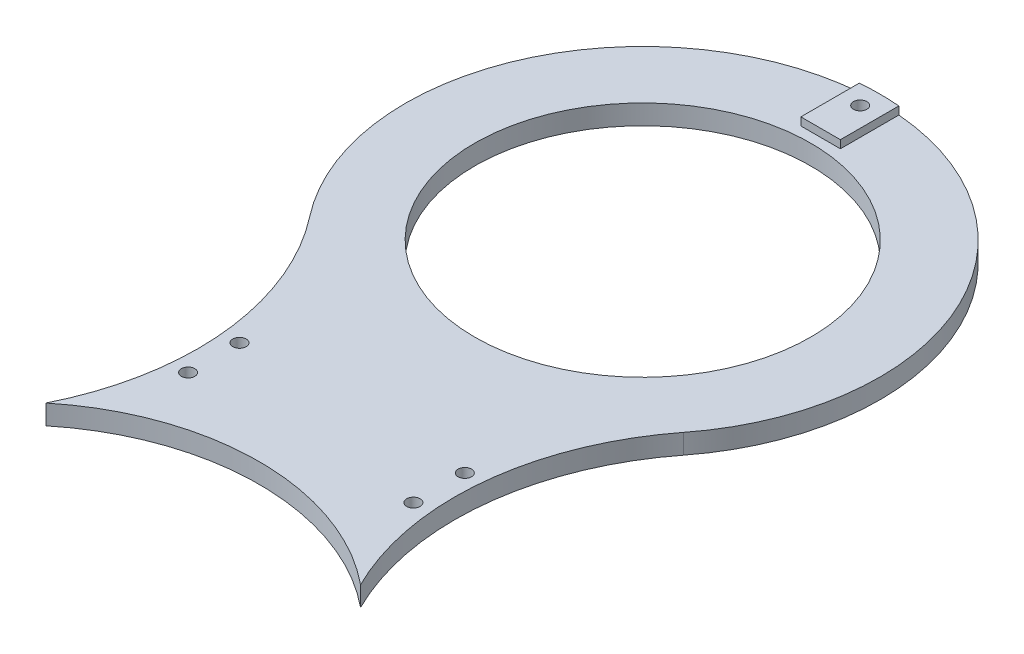
from build123d import *

# Parameters (mm, degrees)
CROQUIS1_R              = 42.5
SALIENTE_EXTRUIR1_DEPTH = 5
SALIENTE_EXTRUIR2_DEPTH = 2
CROQUIS3_R              = 1.7
CORTAR_EXTRUIR1_DEPTH   = 21
CROQUIS4_R              = 2.95
CORTAR_EXTRUIR2_DEPTH   = 3


with BuildPart() as part:
    # Croquis1 → Saliente-Extruir1 (new body)
    with BuildSketch(Plane(origin=(0, 0, 0), x_dir=(1, 0, 0), z_dir=(0, 1, 0))):
        with BuildLine():
            ThreePointArc((39.782879484, 48.85), (0, 63), (-39.782879484, 48.85))
            ThreePointArc((-39.782879484, 48.85), (-32.82545617, 87.047566078), (-47.293763221, 123.077107909))
            ThreePointArc((-47.293763221, 123.077107909), (0, 220), (47.293763221, 123.077107909))
            ThreePointArc((47.293763221, 123.077107909), (32.82545617, 87.047566078), (39.782879484, 48.85))
        make_face()
        with Locations((0, 160)):
            Circle(CROQUIS1_R, mode=Mode.SUBTRACT)
    extrude(amount=SALIENTE_EXTRUIR1_DEPTH)

    # Croquis2 → Saliente-Extruir2 (add)
    with BuildSketch(Plane(origin=(0, 5, 0), x_dir=(1, 0, 0), z_dir=(0, 1, 0))):
        with BuildLine():
            Line((5, 205), (-5, 205))
            Line((-5, 205), (-5, 219.791303716))
            ThreePointArc((-5, 219.791303716), (0, 220), (5, 219.791303716))
            Line((5, 219.791303716), (5, 205))
        make_face()
    extrude(amount=SALIENTE_EXTRUIR2_DEPTH)

    # Croquis3 → Cortar-Extruir1 (cut)
    with BuildSketch(Plane(origin=(0, 7, 0), x_dir=(1, 0, 0), z_dir=(0, 1, 0))):
        with Locations((0, 215)):
            Circle(CROQUIS3_R)
        with Locations((-28.5, 86.5)):
            Circle(CROQUIS3_R)
        with Locations((-28.5, 73.5)):
            Circle(CROQUIS3_R)
        with Locations((28.5, 73.5)):
            Circle(CROQUIS3_R)
        with Locations((28.5, 86.5)):
            Circle(CROQUIS3_R)
    extrude(amount=-CORTAR_EXTRUIR1_DEPTH, mode=Mode.SUBTRACT)

    # Croquis4 → Cortar-Extruir2 (cut)
    with BuildSketch(Plane.XZ):
        with Locations((0, -215)):
            Circle(CROQUIS4_R)
    extrude(amount=-CORTAR_EXTRUIR2_DEPTH, mode=Mode.SUBTRACT)


solid = part.part
